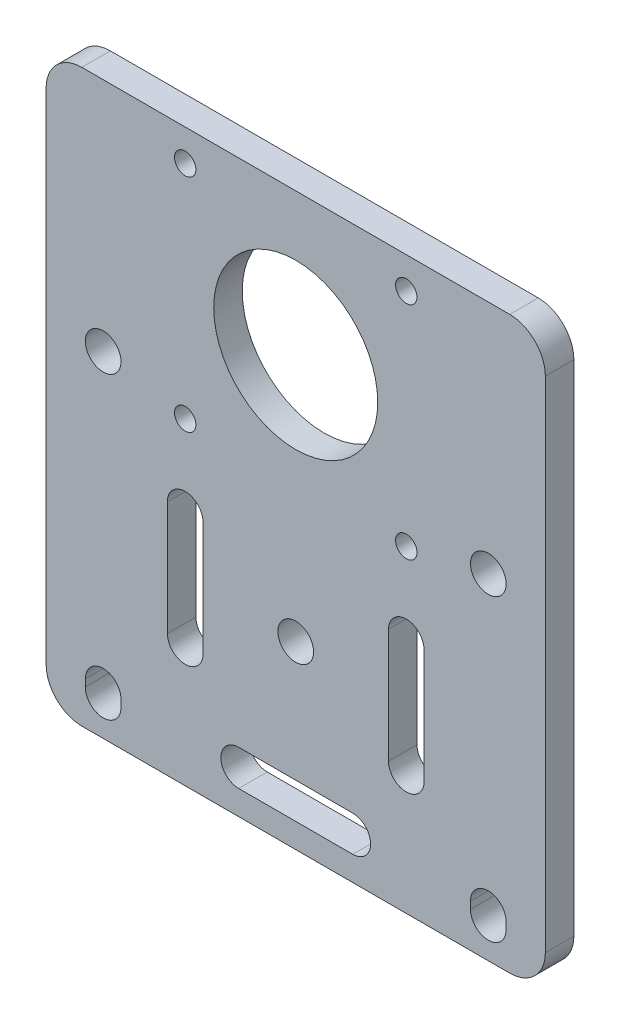
from build123d import *

# Parameters (mm, degrees)
SKETCH4_W           = 70
SKETCH4_H           = 80
SKETCH4_R           = 2.5
BOSS_EXTRUDE2_DEPTH = 4
SKETCH5_R           = 11.5
SKETCH5_R_2         = 1.5
SKETCH5_R_3         = 2.5
CUT_EXTRUDE2_DEPTH  = 5
FILLET1_R           = 5


with BuildPart() as part:
    # Sketch4 → Boss-Extrude2 (new body)
    with BuildSketch(Plane.XY):
        Rectangle(SKETCH4_W, SKETCH4_H)
        with Locations((-27, 7)):
            Circle(SKETCH4_R, mode=Mode.SUBTRACT)
        with Locations((27, 7)):
            Circle(SKETCH4_R, mode=Mode.SUBTRACT)
        with BuildLine():
            Line((-24.5, -34), (-24.5, -35))
            ThreePointArc((-24.5, -35), (-27, -37.5), (-29.5, -35))
            Line((-29.5, -35), (-29.5, -34))
            ThreePointArc((-29.5, -34), (-27, -31.5), (-24.5, -34))
        make_face(mode=Mode.SUBTRACT)
        with BuildLine():
            Line((24.5, -34), (24.5, -35))
            ThreePointArc((24.5, -35), (27, -37.5), (29.5, -35))
            Line((29.5, -35), (29.5, -34))
            ThreePointArc((29.5, -34), (27, -31.5), (24.5, -34))
        make_face(mode=Mode.SUBTRACT)
    extrude(amount=BOSS_EXTRUDE2_DEPTH)

    # Sketch5 → Cut-Extrude2 (cut, through all)
    with BuildSketch(Plane.XY.offset(4)):
        with Locations((0, 20.076696831)):
            Circle(SKETCH5_R)
        with Locations((-15.5, 35.576696831)):
            Circle(SKETCH5_R_2)
        with Locations((15.5, 35.576696831)):
            Circle(SKETCH5_R_2)
        with Locations((15.5, 4.576696831)):
            Circle(SKETCH5_R_2)
        with Locations((-15.5, 4.576696831)):
            Circle(SKETCH5_R_2)
        with Locations((0, -14.75)):
            Circle(SKETCH5_R_3)
        with BuildLine():
            Line((-8, -31.570071963), (8, -31.570071963))
            ThreePointArc((8, -31.570071963), (10.5, -34.070071963), (8, -36.570071963))
            Line((8, -36.570071963), (-8, -36.570071963))
            ThreePointArc((-8, -36.570071963), (-10.5, -34.070071963), (-8, -31.570071963))
        make_face()
        with BuildLine():
            Line((-13, -6.75), (-13, -22.75))
            ThreePointArc((-13, -22.75), (-15.5, -25.25), (-18, -22.75))
            Line((-18, -22.75), (-18, -6.75))
            ThreePointArc((-18, -6.75), (-15.5, -4.25), (-13, -6.75))
        make_face()
        with BuildLine():
            Line((13, -6.75), (13, -22.75))
            ThreePointArc((13, -22.75), (15.5, -25.25), (18, -22.75))
            Line((18, -22.75), (18, -6.75))
            ThreePointArc((18, -6.75), (15.5, -4.25), (13, -6.75))
        make_face()
    extrude(amount=-CUT_EXTRUDE2_DEPTH, mode=Mode.SUBTRACT)

    # Fillet1
    fillet1_edges = [part.edges().sort_by_distance(p)[0] for p in [
        (35, -40, 2),
        (-35, -40, 2),
        (-35, 40, 2),
        (35, 40, 2),
    ]]
    fillet(fillet1_edges, radius=FILLET1_R)


solid = part.part
